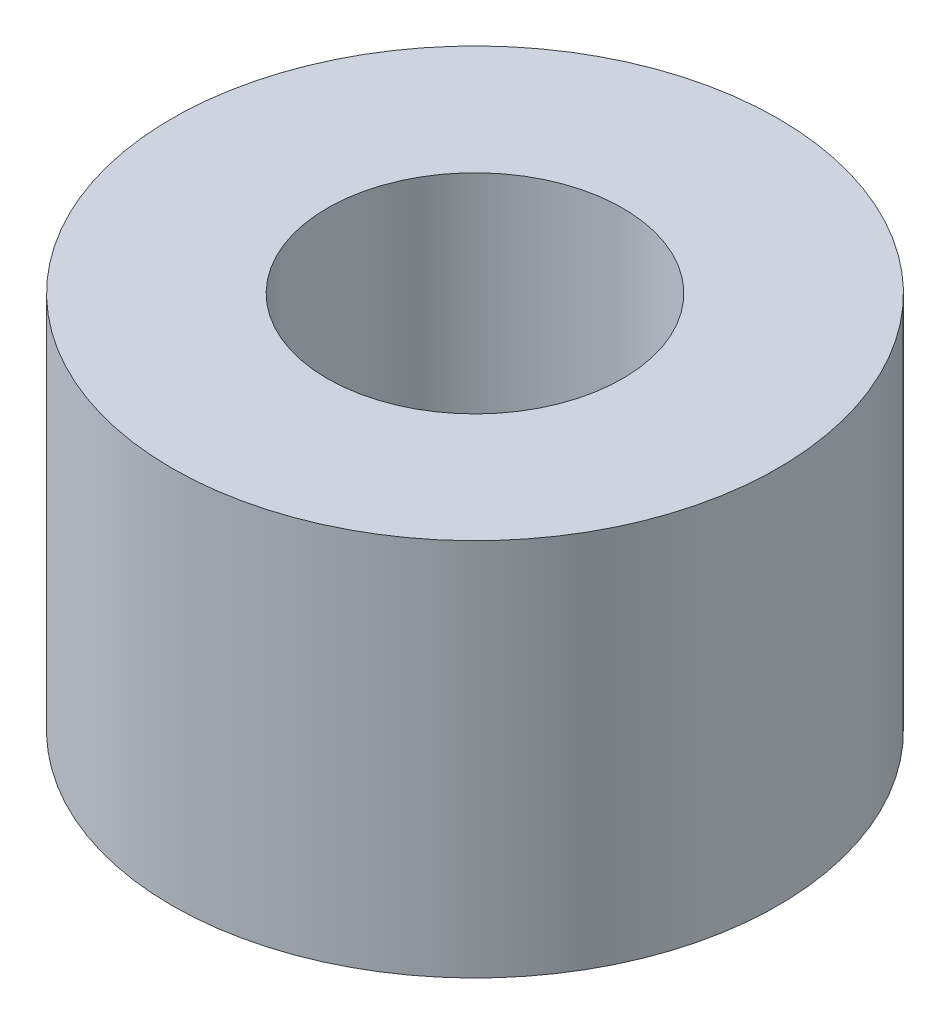
from build123d import *

# Parameters (mm, degrees)
SKETCH_1_R      = 4
SKETCH_1_R_2    = 1.95
EXTRUDE_1_DEPTH = 5


with BuildPart() as part:
    # 草图1 → 凸台-拉伸1 (new body)
    with BuildSketch(Plane(origin=(0, 0, 0), x_dir=(1, 0, 0), z_dir=(0, 1, 0))):
        Circle(SKETCH_1_R)
        Circle(SKETCH_1_R_2, mode=Mode.SUBTRACT)
    extrude(amount=EXTRUDE_1_DEPTH)


solid = part.part
